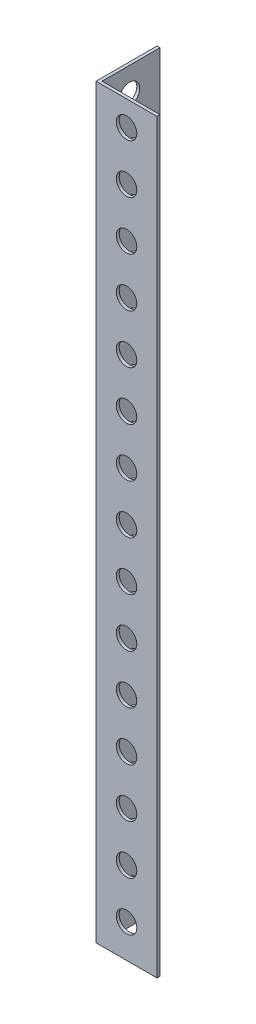
from build123d import *

# Parameters (mm, degrees)
BOSS_EXTRUDE2_DEPTH = 388.752
SKETCH2_R           = 5.35
CUT_EXTRUDE1_DEPTH  = 32.75
SKETCH3_R           = 5.35
CUT_EXTRUDE2_DEPTH  = 32.75
LPATTERN2_COUNT     = 15
LPATTERN2_PITCH     = 25.6


with BuildPart() as part:
    # Sketch1 → Boss-Extrude2 (new body)
    with BuildSketch(Plane(origin=(0, 0, 0), x_dir=(1, 0, 0), z_dir=(0, 1, 0))):
        Polygon((0, 0), (31.75, 0), (31.75, 1.54), (1.54, 1.54), (1.54, 31.75), (0, 31.75), align=None)
    extrude(amount=BOSS_EXTRUDE2_DEPTH)

    # Sketch2 → Cut-Extrude1 (cut, through all)
    with BuildSketch(Plane.ZY):
        with Locations((-15.875, 375.752)):
            Circle(SKETCH2_R)
    cut_extrude1 = extrude(amount=-CUT_EXTRUDE1_DEPTH, mode=Mode.SUBTRACT)

    # Sketch3 → Cut-Extrude2 (cut, through all)
    with BuildSketch(Plane.XY):
        with Locations((15.875, 375.752)):
            Circle(SKETCH3_R)
    cut_extrude2 = extrude(amount=-CUT_EXTRUDE2_DEPTH, mode=Mode.SUBTRACT)

    # LPattern2: Cut-Extrude1, Cut-Extrude2 ×15
    with Locations(*[(0, -i * LPATTERN2_PITCH, 0) for i in range(1, LPATTERN2_COUNT)]):
        add(cut_extrude1, mode=Mode.SUBTRACT)
        add(cut_extrude2, mode=Mode.SUBTRACT)


solid = part.part
